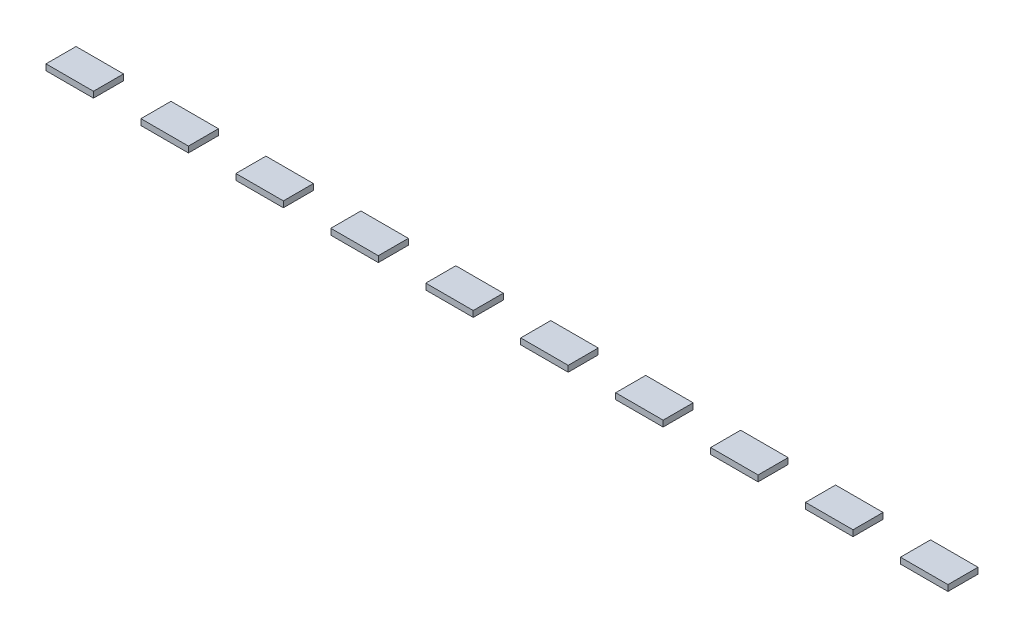
from build123d import *

# Parameters (mm, degrees)
SKETCH1_W              = 20.066
SKETCH1_H              = 12.7
BOSS_EXTRUDE1_DEPTH    = 2.54
BOSS_EXTRUDE1_2_DEPTH  = 2.54
BOSS_EXTRUDE1_3_DEPTH  = 2.54
BOSS_EXTRUDE1_4_DEPTH  = 2.54
BOSS_EXTRUDE1_5_DEPTH  = 2.54
BOSS_EXTRUDE1_6_DEPTH  = 2.54
BOSS_EXTRUDE1_7_DEPTH  = 2.54
BOSS_EXTRUDE1_8_DEPTH  = 2.54
BOSS_EXTRUDE1_9_DEPTH  = 2.54
BOSS_EXTRUDE1_10_DEPTH = 2.54


with BuildPart() as part:
    # Sketch1 → Boss-Extrude1 (new body)
    with BuildSketch(Plane(origin=(0, 0, 0), x_dir=(1, 0, 0), z_dir=(0, 1, 0))):
        with Locations((40.132, 0)):
            Rectangle(SKETCH1_W, SKETCH1_H)
    extrude(amount=BOSS_EXTRUDE1_DEPTH)


with BuildPart() as body_2:
    # Sketch1 → Boss-Extrude1 2 (new body)
    with BuildSketch(Plane(origin=(0, 0, 0), x_dir=(1, 0, 0), z_dir=(0, 1, 0))):
        Rectangle(SKETCH1_W, SKETCH1_H)
    extrude(amount=BOSS_EXTRUDE1_2_DEPTH)


with BuildPart() as body_3:
    # Sketch1 → Boss-Extrude1 3 (new body)
    with BuildSketch(Plane(origin=(0, 0, 0), x_dir=(1, 0, 0), z_dir=(0, 1, 0))):
        with Locations((80.264, 0)):
            Rectangle(SKETCH1_W, SKETCH1_H)
    extrude(amount=BOSS_EXTRUDE1_3_DEPTH)


with BuildPart() as body_4:
    # Sketch1 → Boss-Extrude1 4 (new body)
    with BuildSketch(Plane(origin=(0, 0, 0), x_dir=(1, 0, 0), z_dir=(0, 1, 0))):
        with Locations((120.396, 0)):
            Rectangle(SKETCH1_W, SKETCH1_H)
    extrude(amount=BOSS_EXTRUDE1_4_DEPTH)


with BuildPart() as body_5:
    # Sketch1 → Boss-Extrude1 5 (new body)
    with BuildSketch(Plane(origin=(0, 0, 0), x_dir=(1, 0, 0), z_dir=(0, 1, 0))):
        with Locations((160.528, 0)):
            Rectangle(SKETCH1_W, SKETCH1_H)
    extrude(amount=BOSS_EXTRUDE1_5_DEPTH)


with BuildPart() as body_6:
    # Sketch1 → Boss-Extrude1 6 (new body)
    with BuildSketch(Plane(origin=(0, 0, 0), x_dir=(1, 0, 0), z_dir=(0, 1, 0))):
        with Locations((200.66, 0)):
            Rectangle(SKETCH1_W, SKETCH1_H)
    extrude(amount=BOSS_EXTRUDE1_6_DEPTH)


with BuildPart() as body_7:
    # Sketch1 → Boss-Extrude1 7 (new body)
    with BuildSketch(Plane(origin=(0, 0, 0), x_dir=(1, 0, 0), z_dir=(0, 1, 0))):
        with Locations((240.792, 0)):
            Rectangle(SKETCH1_W, SKETCH1_H)
    extrude(amount=BOSS_EXTRUDE1_7_DEPTH)


with BuildPart() as body_8:
    # Sketch1 → Boss-Extrude1 8 (new body)
    with BuildSketch(Plane(origin=(0, 0, 0), x_dir=(1, 0, 0), z_dir=(0, 1, 0))):
        with Locations((280.924, 0)):
            Rectangle(SKETCH1_W, SKETCH1_H)
    extrude(amount=BOSS_EXTRUDE1_8_DEPTH)


with BuildPart() as body_9:
    # Sketch1 → Boss-Extrude1 9 (new body)
    with BuildSketch(Plane(origin=(0, 0, 0), x_dir=(1, 0, 0), z_dir=(0, 1, 0))):
        with Locations((321.056, 0)):
            Rectangle(SKETCH1_W, SKETCH1_H)
    extrude(amount=BOSS_EXTRUDE1_9_DEPTH)


with BuildPart() as body_10:
    # Sketch1 → Boss-Extrude1 10 (new body)
    with BuildSketch(Plane(origin=(0, 0, 0), x_dir=(1, 0, 0), z_dir=(0, 1, 0))):
        with Locations((361.188, 0)):
            Rectangle(SKETCH1_W, SKETCH1_H)
    extrude(amount=BOSS_EXTRUDE1_10_DEPTH)


solid = Compound([part.part, body_2.part, body_3.part, body_4.part, body_5.part, body_6.part, body_7.part, body_8.part, body_9.part, body_10.part])
